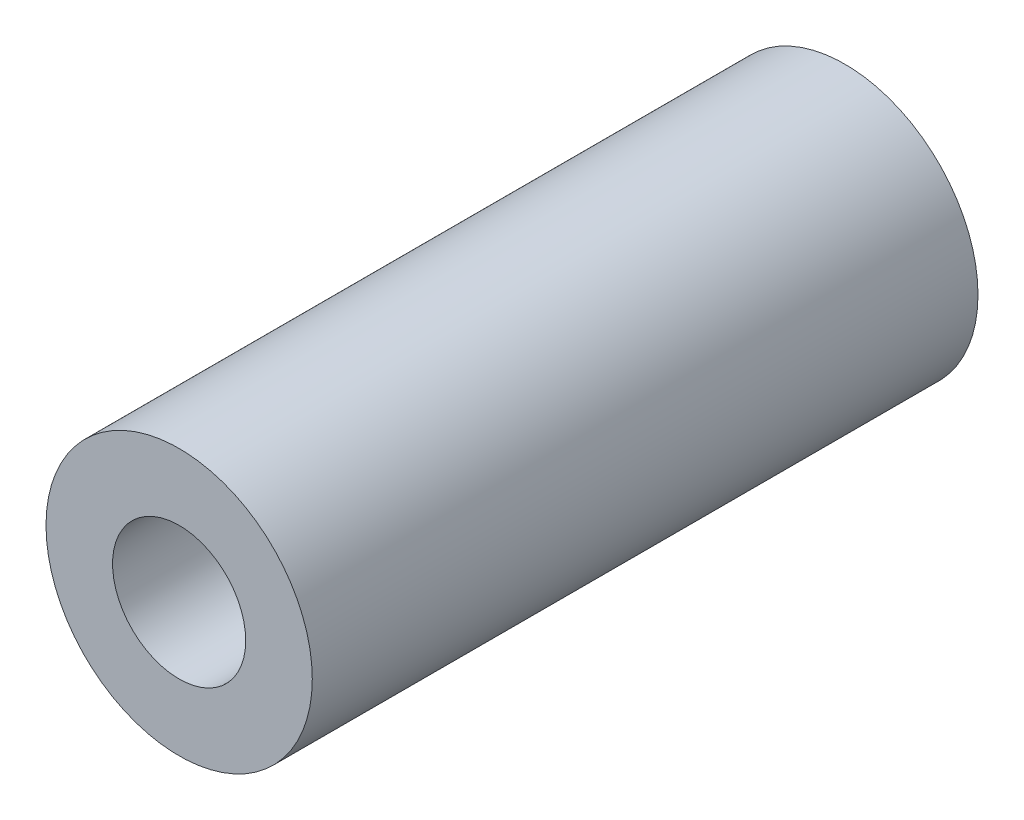
from build123d import *

# Parameters (mm, degrees)
SKETCH1_R           = 2
SKETCH1_R_2         = 1
EXTRUDE_THIN1_DEPTH = 10


with BuildPart() as part:
    # Sketch1 → Extrude-Thin1 (new body)
    with BuildSketch(Plane.XY):
        Circle(SKETCH1_R)
        Circle(SKETCH1_R_2, mode=Mode.SUBTRACT)
    extrude(amount=EXTRUDE_THIN1_DEPTH)


solid = part.part
